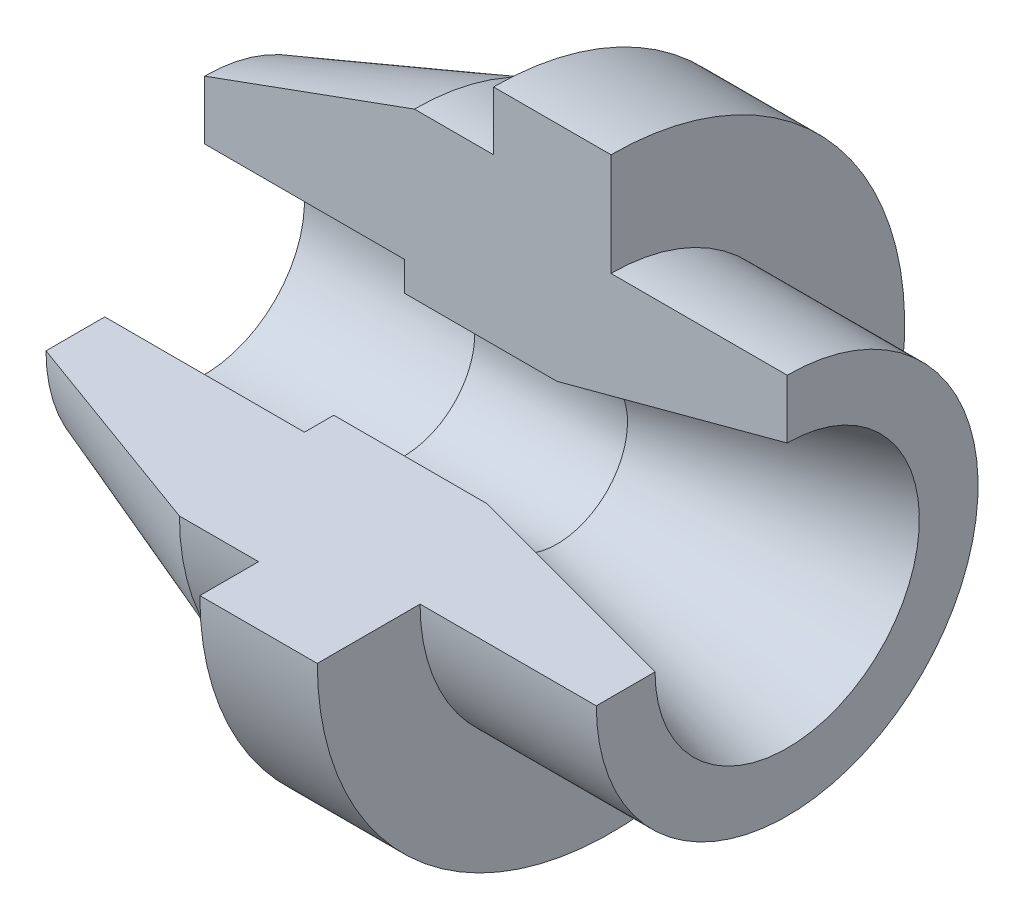
from build123d import *

# Parameters (mm, degrees)
REVOLVE1_ANGLE = 270


with BuildPart() as part:
    # Sketch1 → Revolve1 (revolve)
    with BuildSketch(Plane(origin=(0, 0, 0), x_dir=(1, 0, 0), z_dir=(0, 1, 0))):
        Polygon((0, -17), (0, -27), (35.717206453, -40), (49.186533479, -40), (49.186533479, -50), (69.186533479, -50), (69.186533479, -32.5), (99.186533479, -32.5), (99.186533479, -22.5), (60, -12), (34, -12), (34, -17), align=None)
    revolve(axis=Axis((0, 0, 0), (1, 0, 0)), revolution_arc=REVOLVE1_ANGLE)


solid = part.part
